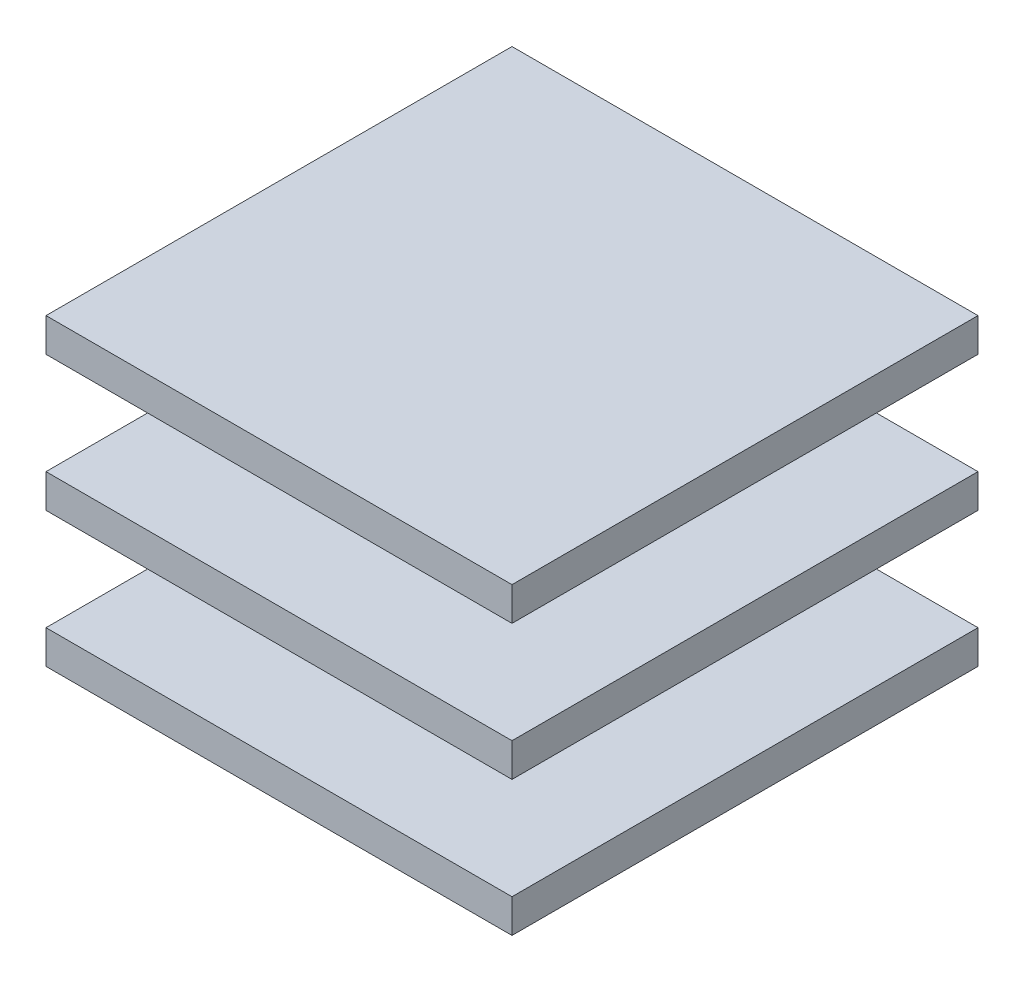
from build123d import *

# Parameters (mm, degrees)
ESQUISSE1_W      = 250
ESQUISSE1_H      = 250
EXTRUSION1_DEPTH = 18
ESQUISSE2_W      = 70
ESQUISSE2_H      = 70
EXTRUSION2_DEPTH = 54.5
ESQUISSE3_W      = 250
ESQUISSE3_H      = 250
EXTRUSION3_DEPTH = 18
ESQUISSE4_W      = 70
ESQUISSE4_H      = 70
EXTRUSION4_DEPTH = 54.5
ESQUISSE5_W      = 250
ESQUISSE5_H      = 250
EXTRUSION5_DEPTH = 18


with BuildPart() as part:
    # Esquisse1 → Extrusion1 (new body)
    with BuildSketch(Plane(origin=(0, 0, 0), x_dir=(1, 0, 0), z_dir=(0, 1, 0))):
        with Locations((125, 125)):
            Rectangle(ESQUISSE1_W, ESQUISSE1_H)
    extrude(amount=EXTRUSION1_DEPTH)

    # Esquisse2 → Extrusion2 (add)
    with BuildSketch(Plane(origin=(0, 18, 0), x_dir=(-1, 0, 0), z_dir=(0, 1, 0))):
        with Locations((-125, -125)):
            Rectangle(ESQUISSE2_W, ESQUISSE2_H)
    extrude(amount=EXTRUSION2_DEPTH)

    # Esquisse3 → Extrusion3 (add)
    with BuildSketch(Plane(origin=(0, 72.5, 0), x_dir=(1, 0, 0), z_dir=(0, 1, 0))):
        with Locations((125, 125)):
            Rectangle(ESQUISSE3_W, ESQUISSE3_H)
    extrude(amount=EXTRUSION3_DEPTH)

    # Esquisse4 → Extrusion4 (add)
    with BuildSketch(Plane(origin=(0, 90.5, 0), x_dir=(1, 0, 0), z_dir=(0, 1, 0))):
        with Locations((125, 125)):
            Rectangle(ESQUISSE4_W, ESQUISSE4_H)
    extrude(amount=EXTRUSION4_DEPTH)

    # Esquisse5 → Extrusion5 (add)
    with BuildSketch(Plane(origin=(0, 145, 0), x_dir=(1, 0, 0), z_dir=(0, 1, 0))):
        with Locations((125, 125)):
            Rectangle(ESQUISSE5_W, ESQUISSE5_H)
    extrude(amount=EXTRUSION5_DEPTH)


solid = part.part
